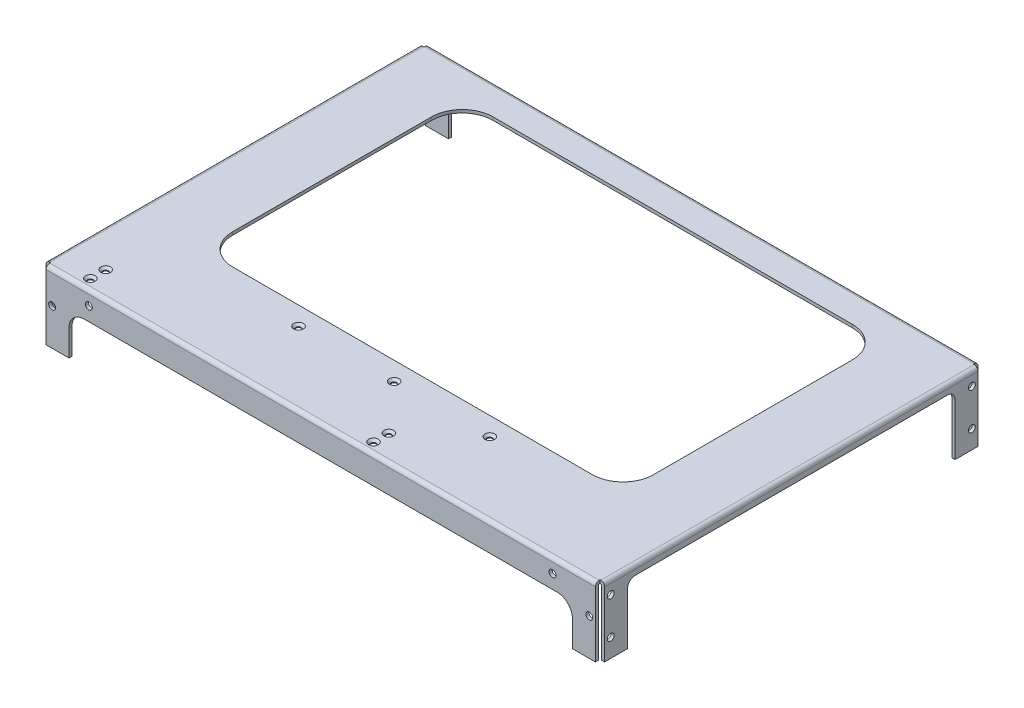
from build123d import *

# Parameters (mm, degrees)
BOSS_EXTRUDE1_DEPTH                             = 182.5
CUT_EXTRUDE1_DEPTH                              = 251
CUT_EXTRUDE2_DEPTH                              = 10
SKETCH4_W                                       = 2
SKETCH4_H                                       = 246
BOSS_EXTRUDE2_DEPTH                             = 43
SKETCH5_W                                       = 3
SKETCH5_H                                       = 3
CUT_EXTRUDE3_DEPTH                              = 46
FILLET1_R                                       = 0.5
FILLET2_R                                       = 2.5
CUT_EXTRUDE6_DEPTH                              = 366
SKETCH9_R                                       = 2.25
CUT_EXTRUDE7_DEPTH                              = 366
SKETCH10_R                                      = 2.25
CUT_EXTRUDE8_DEPTH                              = 10
SKETCH11_R                                      = 2.25
CUT_EXTRUDE9_DEPTH                              = 10
SKETCH12_R                                      = 1.5
CUT_EXTRUDE10_DEPTH                             = 10
CSK_FOR_M3_FLAT_HEAD_MACHINE_SCREW1_D           = 3.4
CSK_FOR_M3_FLAT_HEAD_MACHINE_SCREW1_CSINK_D     = 6.3
CSK_FOR_M3_FLAT_HEAD_MACHINE_SCREW1_CSINK_ANGLE = 90


with BuildPart() as part:
    # Sketch1 → Boss-Extrude1 (new body, symmetric)
    with BuildSketch(Plane(origin=(0, 0, 0), x_dir=(0, 0, -1), z_dir=(1, 0, 0))):
        with BuildLine():
            Line((123, -45), (125, -45))
            Line((125, -45), (125, -2.5))
            ThreePointArc((125, -2.5), (124.267766953, -0.732233047), (122.5, 0))
            Line((122.5, 0), (-122.5, 0))
            ThreePointArc((-122.5, 0), (-124.267766953, -0.732233047), (-125, -2.5))
            Line((-125, -2.5), (-125, -45))
            Line((-125, -45), (-123, -45))
            Line((-123, -45), (-123, -2.5))
            ThreePointArc((-123, -2.5), (-122.853553391, -2.146446609), (-122.5, -2))
            Line((-122.5, -2), (122.5, -2))
            ThreePointArc((122.5, -2), (122.853553391, -2.146446609), (123, -2.5))
            Line((123, -2.5), (123, -45))
        make_face()
    extrude(amount=BOSS_EXTRUDE1_DEPTH, both=True)

    # Sketch2 → Cut-Extrude1 (cut, through all)
    with BuildSketch(Plane.XY.offset(125)):
        with BuildLine():
            Line((-164.5, -45), (164.5, -45))
            Line((164.5, -45), (164.5, -28))
            ThreePointArc((164.5, -28), (161.571067812, -20.928932188), (154.5, -18))
            Line((154.5, -18), (-154.5, -18))
            ThreePointArc((-154.5, -18), (-161.571067812, -20.928932188), (-164.5, -28))
            Line((-164.5, -28), (-164.5, -45))
        make_face()
    extrude(amount=-CUT_EXTRUDE1_DEPTH, mode=Mode.SUBTRACT)

    # Sketch3 → Cut-Extrude2 (cut)
    with BuildSketch(Plane(origin=(0, 0, 0), x_dir=(1, 0, 0), z_dir=(0, 1, 0))):
        with BuildLine():
            Line((-117.5, 105), (117.5, 105))
            ThreePointArc((117.5, 105), (131.642135624, 99.142135624), (137.5, 85))
            Line((137.5, 85), (137.5, -45))
            ThreePointArc((137.5, -45), (131.642135624, -59.142135624), (117.5, -65))
            Line((117.5, -65), (-117.5, -65))
            ThreePointArc((-117.5, -65), (-131.642135624, -59.142135624), (-137.5, -45))
            Line((-137.5, -45), (-137.5, 85))
            ThreePointArc((-137.5, 85), (-131.642135624, 99.142135624), (-117.5, 105))
        make_face()
    extrude(amount=-CUT_EXTRUDE2_DEPTH, mode=Mode.SUBTRACT)

    # Sketch4 → Boss-Extrude2 (add)
    with BuildSketch(Plane.XZ.offset(2)):
        with Locations((-181.5, 0)):
            Rectangle(SKETCH4_W, SKETCH4_H)
        with Locations((181.5, 0)):
            Rectangle(SKETCH4_W, SKETCH4_H)
    extrude(amount=BOSS_EXTRUDE2_DEPTH)

    # Sketch5 → Cut-Extrude3 (cut, through all)
    with BuildSketch(Plane.XZ.offset(45)):
        with Locations((-181, 123.5)):
            Rectangle(SKETCH5_W, SKETCH5_H)
        with Locations((-181, -123.5)):
            Rectangle(SKETCH5_W, SKETCH5_H)
        with Locations((181, -123.5)):
            Rectangle(SKETCH5_W, SKETCH5_H)
        with Locations((181, 123.5)):
            Rectangle(SKETCH5_W, SKETCH5_H)
    extrude(amount=-CUT_EXTRUDE3_DEPTH, mode=Mode.SUBTRACT)

    # Fillet1
    fillet1_edges = [part.edges().sort_by_distance(p)[0] for p in [
        (-180.5, -2, 0),
        (180.5, -2, 0),
    ]]
    fillet(fillet1_edges, radius=FILLET1_R)

    # Fillet2
    fillet2_edges = [part.edges().sort_by_distance(p)[0] for p in [
        (-182.5, 0, 0),
        (182.5, 0, 0),
    ]]
    fillet(fillet2_edges, radius=FILLET2_R)

    # Sketch8 → Cut-Extrude6 (cut, through all)
    with BuildSketch(Plane.ZY.offset(182.5)):
        with BuildLine():
            Line((-107, -45), (107, -45))
            Line((107, -45), (107, -11))
            ThreePointArc((107, -11), (105.535533906, -7.464466094), (102, -6))
            Line((102, -6), (-102, -6))
            ThreePointArc((-102, -6), (-105.535533906, -7.464466094), (-107, -11))
            Line((-107, -11), (-107, -45))
        make_face()
    extrude(amount=-CUT_EXTRUDE6_DEPTH, mode=Mode.SUBTRACT)

    # Sketch9 → Cut-Extrude7 (cut, through all)
    with BuildSketch(Plane.ZY.offset(182.5)):
        with Locations((-118, -9)):
            Circle(SKETCH9_R)
        with Locations((-118, -33)):
            Circle(SKETCH9_R)
        with Locations((118, -9)):
            Circle(SKETCH9_R)
        with Locations((118, -33)):
            Circle(SKETCH9_R)
    extrude(amount=-CUT_EXTRUDE7_DEPTH, mode=Mode.SUBTRACT)

    # Sketch10 → Cut-Extrude8 (cut)
    with BuildSketch(Plane.XY.offset(125)):
        with Locations((-151.5, -9)):
            Circle(SKETCH10_R)
        with Locations((175.5, -21)):
            Circle(SKETCH10_R)
        with Locations((151.5, -9)):
            Circle(SKETCH10_R)
        with Locations((-175.5, -21)):
            Circle(SKETCH10_R)
    extrude(amount=-CUT_EXTRUDE8_DEPTH, mode=Mode.SUBTRACT)

    # Sketch11 → Cut-Extrude9 (cut)
    with BuildSketch(Plane(origin=(0, 0, -125), x_dir=(-1, 0, 0), z_dir=(0, 0, -1))):
        with Locations(Location((-175.5, -21, 0), (0, 0, 180))):  # turned: the seam where the file's is
            Circle(SKETCH11_R)
        with Locations(Location((-151.5, -9, 0), (0, 0, 180))):  # turned: the seam where the file's is
            Circle(SKETCH11_R)
        with Locations(Location((151.5, -9, 0), (0, 0, 180))):  # turned: the seam where the file's is
            Circle(SKETCH11_R)
        with Locations(Location((175.5, -21, 0), (0, 0, 180))):  # turned: the seam where the file's is
            Circle(SKETCH11_R)
    extrude(amount=-CUT_EXTRUDE9_DEPTH, mode=Mode.SUBTRACT)

    # Sketch12 → Cut-Extrude10 (cut)
    with BuildSketch(Plane(origin=(0, 0, 0), x_dir=(1, 0, 0), z_dir=(0, 1, 0))):
        with Locations(Location((0, -77, 0), (0, 0, 270))):  # turned: the seam where the file's is
            Circle(SKETCH12_R)
        with Locations(Location((62.5, -77, 0), (0, 0, 270))):  # turned: the seam where the file's is
            Circle(SKETCH12_R)
        with Locations(Location((-62.5, -77, 0), (0, 0, 270))):  # turned: the seam where the file's is
            Circle(SKETCH12_R)
        with Locations(Location((-157.5, -108, 0), (0, 0, 270))):  # turned: the seam where the file's is
            Circle(SKETCH12_R)
        with Locations(Location((-157.5, -118, 0), (0, 0, 270))):  # turned: the seam where the file's is
            Circle(SKETCH12_R)
        with Locations(Location((27.5, -108, 0), (0, 0, 270))):  # turned: the seam where the file's is
            Circle(SKETCH12_R)
        with Locations(Location((27.5, -118, 0), (0, 0, 270))):  # turned: the seam where the file's is
            Circle(SKETCH12_R)
    extrude(amount=-CUT_EXTRUDE10_DEPTH, mode=Mode.SUBTRACT)

    # CSK for M3 Flat Head Machine Screw1 (through all)
    with Locations(Plane(origin=(0, 0, 0), x_dir=(-1, 0, 0), z_dir=(0, 1, 0))):
        with Locations((62.5, 77), (0, 77), (-62.5, 77), (157.5, 108), (157.5, 118), (-27.5, 108), (-27.5, 118)):
            CounterSinkHole(CSK_FOR_M3_FLAT_HEAD_MACHINE_SCREW1_D / 2, CSK_FOR_M3_FLAT_HEAD_MACHINE_SCREW1_CSINK_D / 2, counter_sink_angle=CSK_FOR_M3_FLAT_HEAD_MACHINE_SCREW1_CSINK_ANGLE)


solid = part.part
